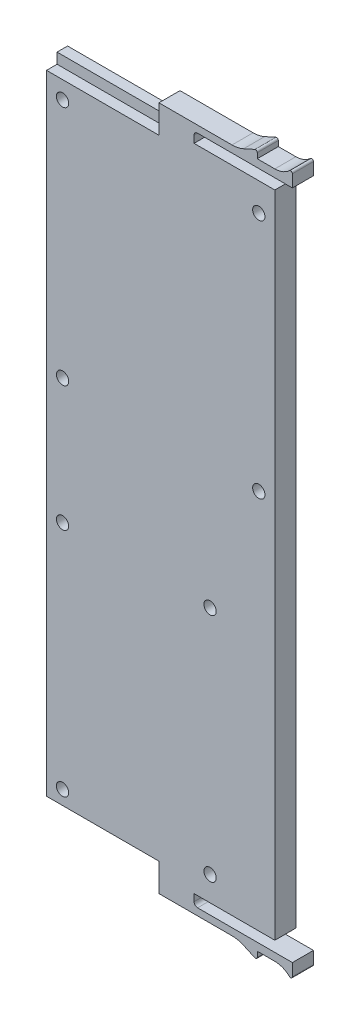
from build123d import *

# Parameters (mm, degrees)
BOSS_EXTRUDE1_DEPTH = 6
SKETCH4_W           = 3
SKETCH4_H           = 3
CUT_EXTRUDE2_DEPTH  = 32
SKETCH5_R           = 1.75
CUT_EXTRUDE3_DEPTH  = 10


with BuildPart() as part:
    # Sketch1 → Boss-Extrude1 (new body)
    with BuildSketch(Plane(origin=(0, 0, 0), x_dir=(0, 1, 0), z_dir=(0, 0, 1))):
        with BuildLine():
            Line((-92.5, -9.5), (-94.5, -9.5))
            ThreePointArc((-94.5, -9.5), (-95.207106781, -9.792893219), (-95.5, -10.5))
            Line((-95.5, -10.5), (-95.5, -27.5))
            Line((-95.5, -27.5), (-95.5, -37.5))
            Line((-95.5, -37.5), (-99, -37.5))
            ThreePointArc((-99, -37.5), (-99.459572515, -37.196959649), (-99.362068966, -36.655172414))
            ThreePointArc((-99.362068966, -36.655172414), (-98.130927937, -34.737628825), (-97.7, -32.5))
            Line((-97.7, -32.5), (-97.7, -27.5))
            Line((-97.7, -27.5), (-99.2, -27.5))
            ThreePointArc((-99.2, -27.5), (-99.620181053, -27.271012699), (-99.655497604, -26.793791532))
            Line((-99.655497604, -26.793791532), (-98.212038328, -23.6053083))
            ThreePointArc((-98.212038328, -23.6053083), (-97.680035378, -21.993620083), (-97.5, -20.305972812))
            Line((-97.5, -20.305972812), (-97.5, -9.5))
            Line((-97.5, -9.5), (-97.5, 0.5))
            Line((-97.5, 0.5), (-92.5, 0.5))
            Line((-92.5, 0.5), (-92.5, 32.5))
            Line((-92.5, 32.5), (92.5, 32.5))
            Line((92.5, 32.5), (92.5, 0.5))
            Line((92.5, 0.5), (97.5, 0.5))
            Line((97.5, 0.5), (97.5, -9.5))
            Line((97.5, -9.5), (97.5, -20.305972812))
            ThreePointArc((97.5, -20.305972812), (97.680035378, -21.993620083), (98.212038328, -23.6053083))
            Line((98.212038328, -23.6053083), (99.655497604, -26.793791532))
            ThreePointArc((99.655497604, -26.793791532), (99.620181053, -27.271012699), (99.2, -27.5))
            Line((99.2, -27.5), (97.7, -27.5))
            Line((97.7, -27.5), (97.7, -32.5))
            ThreePointArc((97.7, -32.5), (98.130927937, -34.737628825), (99.362068966, -36.655172414))
            ThreePointArc((99.362068966, -36.655172414), (99.459572515, -37.196959649), (99, -37.5))
            Line((99, -37.5), (95.5, -37.5))
            Line((95.5, -37.5), (95.5, -27.5))
            Line((95.5, -27.5), (95.5, -10.5))
            ThreePointArc((95.5, -10.5), (95.207106781, -9.792893219), (94.5, -9.5))
            Line((94.5, -9.5), (92.5, -9.5))
            Line((92.5, -9.5), (92.5, -32.5))
            Line((92.5, -32.5), (-92.5, -32.5))
            Line((-92.5, -32.5), (-92.5, -9.5))
        make_face()
    extrude(amount=BOSS_EXTRUDE1_DEPTH)

    # Sketch4 → Cut-Extrude2 (cut)
    with BuildSketch(Plane(origin=(-32.5, 0, 0), x_dir=(0, -1, 0), z_dir=(-1, 0, 0))):
        with Locations((-91, 4.5)):
            Rectangle(SKETCH4_W, SKETCH4_H)
        with Locations((91, 4.5)):
            Rectangle(SKETCH4_W, SKETCH4_H)
    extrude(amount=-CUT_EXTRUDE2_DEPTH, mode=Mode.SUBTRACT)

    # Sketch5 → Cut-Extrude3 (cut)
    with BuildSketch(Plane.XY.offset(6)):
        with Locations((-27.94, 84.5)):
            Circle(SKETCH5_R)
        with Locations((-27.94, 15.92)):
            Circle(SKETCH5_R)
        with Locations((27.94, 15.92)):
            Circle(SKETCH5_R)
        with Locations((27.94, 84.5)):
            Circle(SKETCH5_R)
        with Locations((-27.94, -19.75)):
            Circle(SKETCH5_R)
        with Locations((-27.94, -85.5)):
            Circle(SKETCH5_R)
        with Locations((14.06, -85.5)):
            Circle(SKETCH5_R)
        with Locations((14.06, -19.75)):
            Circle(SKETCH5_R)
    extrude(amount=-CUT_EXTRUDE3_DEPTH, mode=Mode.SUBTRACT)


solid = part.part
